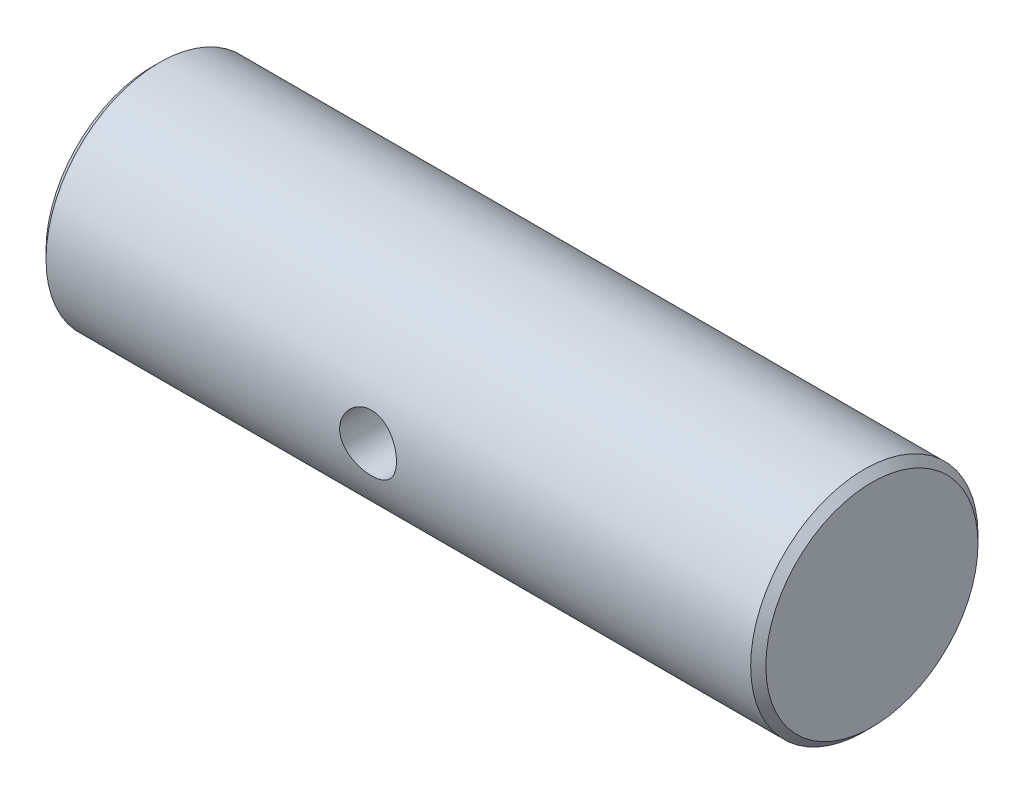
from build123d import *

# Parameters (mm, degrees)
ESQUISSE1_W                  = 19
ESQUISSE1_H                  = 3
CHANFREIN1_SIZE              = 0.2
ESQUISSE2_R                  = 0.75
ENL_V_MAT_EXTRU_1_DEPTH      = 4
ENL_V_MAT_EXTRU_1_DEPTH_BACK = 4


with BuildPart() as part:
    # Esquisse1 → Révolution1 (revolve)
    with BuildSketch(Plane.XY):
        with Locations((-5.5, 1.5)):
            Rectangle(ESQUISSE1_W, ESQUISSE1_H)
    revolve(axis=Axis((-15, 0, 0), (1, 0, 0)))

    # Chanfrein1
    chanfrein1_edges = [part.edges().sort_by_distance(p)[0] for p in [
        (-15, -3, 0),
        (4, -3, 0),
    ]]
    chamfer(chanfrein1_edges, length=CHANFREIN1_SIZE)

    # Esquisse2 → Enlèv. mat.-Extru.1 (cut, two sides)
    with BuildSketch(Plane.XY) as enl_v_mat_extru_1_sk:
        with Locations((-6.3, 0)):
            Circle(ESQUISSE2_R)
    extrude(amount=ENL_V_MAT_EXTRU_1_DEPTH, mode=Mode.SUBTRACT)
    extrude(enl_v_mat_extru_1_sk.sketch, amount=-ENL_V_MAT_EXTRU_1_DEPTH_BACK, mode=Mode.SUBTRACT)


solid = part.part
